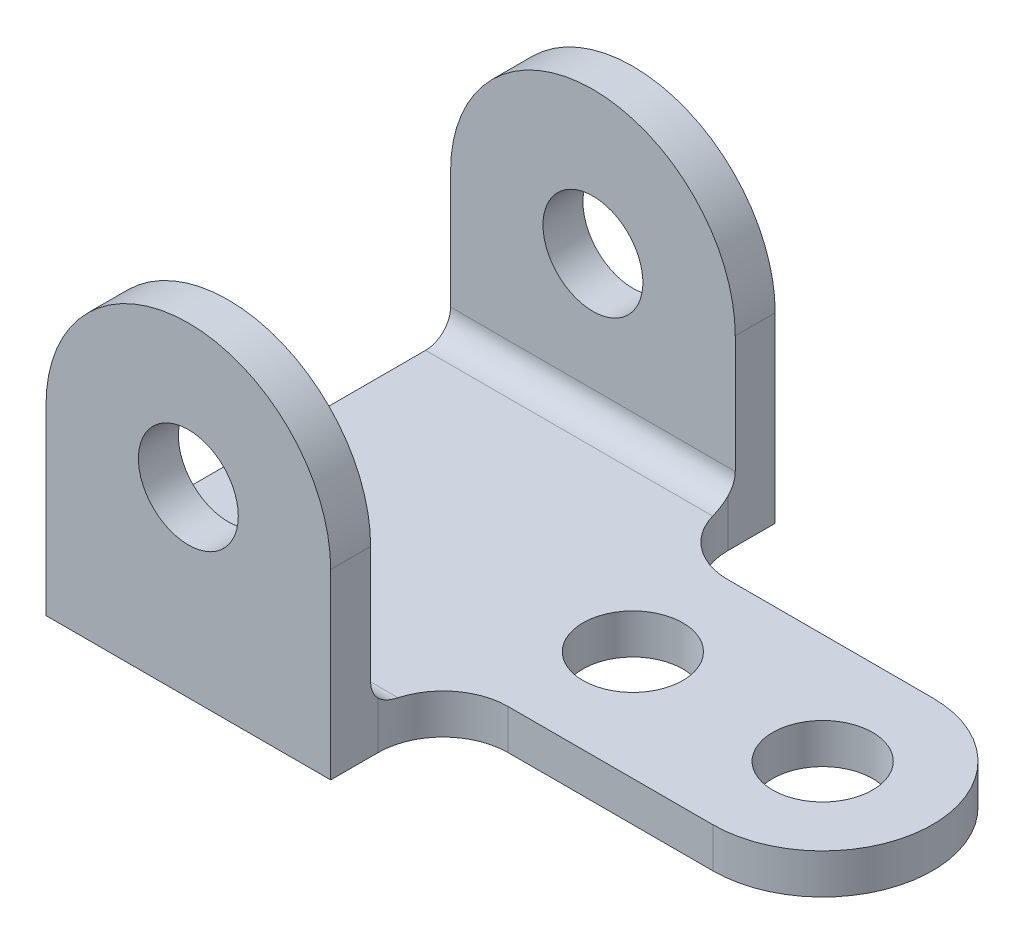
from build123d import *

# Parameters (mm, degrees)
SKETCH2_R           = 10
BOSS_EXTRUDE1_DEPTH = 8
SKETCH3_R           = 10
BOSS_EXTRUDE2_DEPTH = 8
SKETCH4_R           = 10
BOSS_EXTRUDE3_DEPTH = 8
FILLET1_R           = 5


with BuildPart() as part:
    # Sketch2 → Boss-Extrude1 (new body)
    with BuildSketch(Plane(origin=(0, 0, 0), x_dir=(1, 0, 0), z_dir=(0, 1, 0))):
        with BuildLine():
            Line((0, 0), (0, 89))
            Line((0, 89), (57, 89))
            Line((57, 89), (57, 79.5))
            ThreePointArc((57, 79.5), (60.807611845, 70.307611845), (70, 66.5))
            Line((70, 66.5), (111, 66.5))
            ThreePointArc((111, 66.5), (133, 44.5), (111, 22.5))
            Line((111, 22.5), (70, 22.5))
            ThreePointArc((70, 22.5), (60.807611845, 18.692388155), (57, 9.5))
            Line((57, 9.5), (57, 0))
            Line((57, 0), (0, 0))
        make_face()
        with Locations((73, 44.5)):
            Circle(SKETCH2_R, mode=Mode.SUBTRACT)
        with Locations((111, 44.5)):
            Circle(SKETCH2_R, mode=Mode.SUBTRACT)
    extrude(amount=BOSS_EXTRUDE1_DEPTH)

    # Sketch3 → Boss-Extrude2 (add)
    with BuildSketch(Plane.XY):
        with BuildLine():
            Line((0, 0), (57, 0))
            Line((57, 0), (57, 36.5))
            ThreePointArc((57, 36.5), (28.5, 65), (0, 36.5))
            Line((0, 36.5), (0, 0))
        make_face()
        with Locations((28.5, 36.5)):
            Circle(SKETCH3_R, mode=Mode.SUBTRACT)
    extrude(amount=-BOSS_EXTRUDE2_DEPTH)

    # Sketch4 → Boss-Extrude3 (add)
    with BuildSketch(Plane(origin=(0, 0, -89), x_dir=(-1, 0, 0), z_dir=(0, 0, -1))):
        with BuildLine():
            Line((-57, 8), (0, 8))
            Line((0, 8), (0, 36.5))
            ThreePointArc((0, 36.5), (-28.5, 65), (-57, 36.5))
            Line((-57, 36.5), (-57, 8))
        make_face()
        with Locations((-28.5, 36.5)):
            Circle(SKETCH4_R, mode=Mode.SUBTRACT)
    extrude(amount=-BOSS_EXTRUDE3_DEPTH)

    # Fillet1
    fillet1_edges = [part.edges().sort_by_distance(p)[0] for p in [
        (28.5, 8, -8),
        (28.5, 8, -81),
    ]]
    fillet(fillet1_edges, radius=FILLET1_R)


solid = part.part
